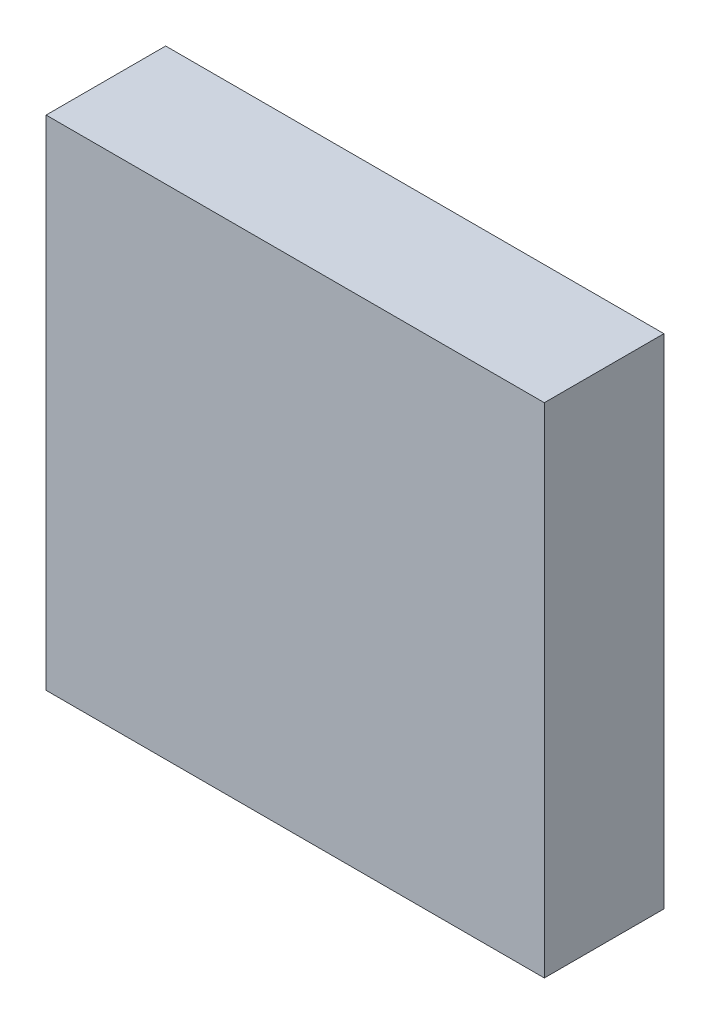
from build123d import *

# Parameters (mm, degrees)
EXTRUDE_1_DEPTH = 6


with BuildPart() as part:
    # 草图1 → 凸台-拉伸1 (new body)
    with BuildSketch(Plane.XY):
        Polygon((208.308771729, 77.293179349), (208.308771729, 89.793179349), (233.308771729, 89.793179349), (233.308771729, 64.793179349), (208.308771729, 64.793179349), align=None)
    extrude(amount=EXTRUDE_1_DEPTH)


solid = part.part
